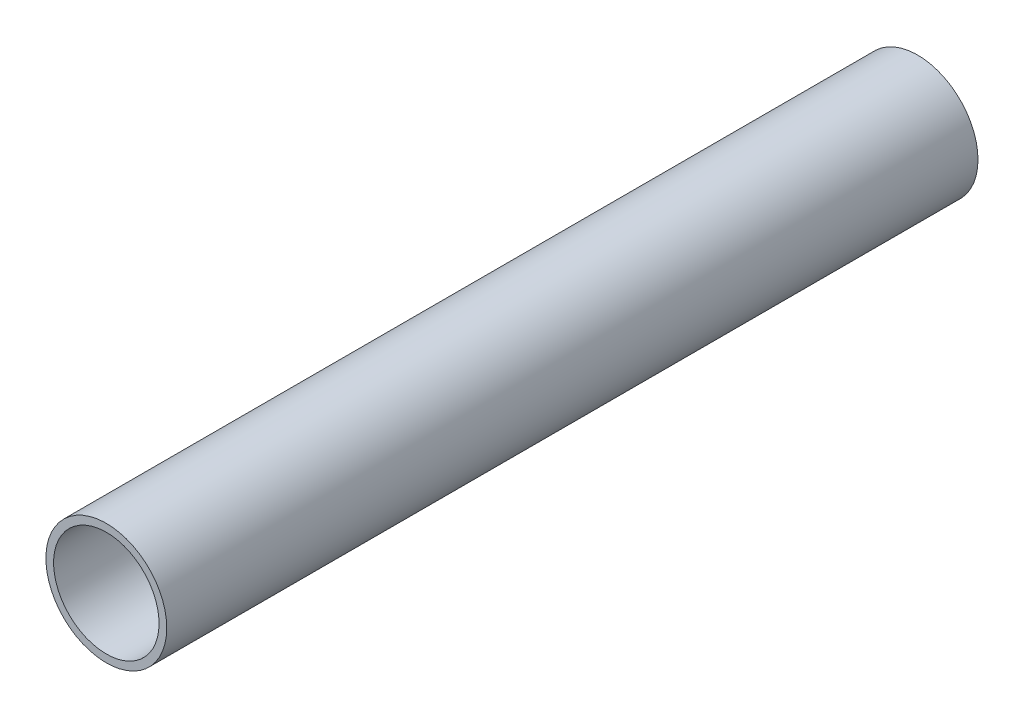
from build123d import *

# Parameters (mm, degrees)
SKETCH1_R           = 18.923
SKETCH1_R_2         = 16.51
BOSS_EXTRUDE1_DEPTH = 254


with BuildPart() as part:
    # Sketch1 → Boss-Extrude1 (new body)
    with BuildSketch(Plane.XY):
        Circle(SKETCH1_R)
        Circle(SKETCH1_R_2, mode=Mode.SUBTRACT)
    extrude(amount=BOSS_EXTRUDE1_DEPTH)


solid = part.part
